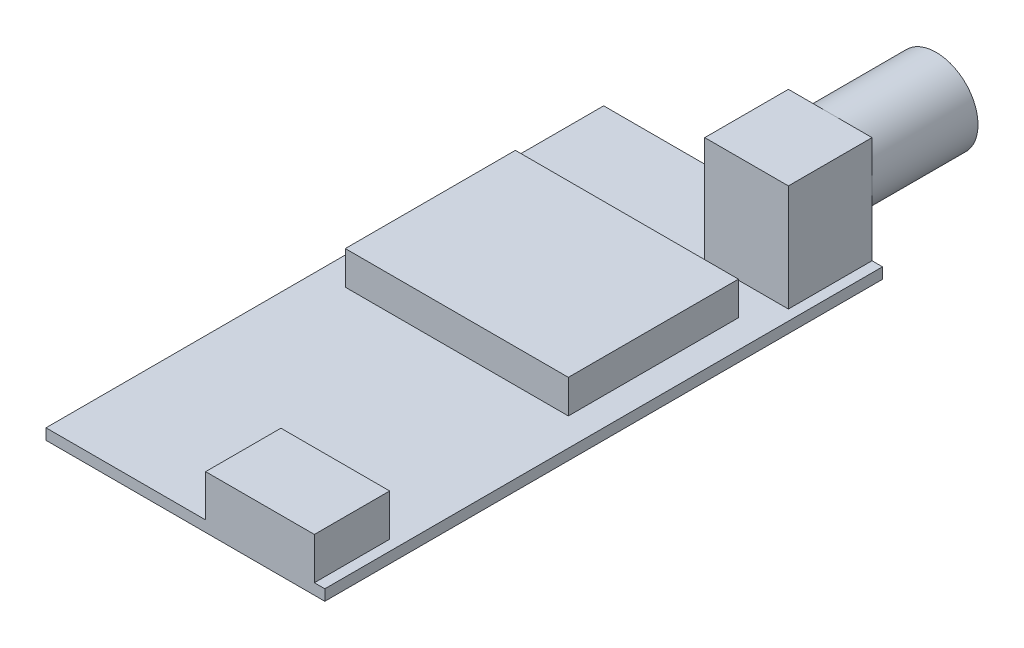
from build123d import *

# Parameters (mm, degrees)
SKETCH1_W           = 20
SKETCH1_H           = 40
BOSS_EXTRUDE1_DEPTH = 0.78
SKETCH4_W           = 6
SKETCH4_H           = 7.65
BOSS_EXTRUDE2_DEPTH = 6
SKETCH4_3_R         = 3
BOSS_EXTRUDE3_DEPTH = 7.6
SKETCH5_W           = 7.8
SKETCH5_H           = 5.4
BOSS_EXTRUDE4_DEPTH = 3
SKETCH6_W           = 16
SKETCH6_H           = 12.2
BOSS_EXTRUDE5_DEPTH = 2.4


with BuildPart() as part:
    # Sketch1 → Boss-Extrude1 (new body)
    with BuildSketch(Plane(origin=(0, 0, 0), x_dir=(1, 0, 0), z_dir=(0, 1, 0))):
        with Locations((0, -20)):
            Rectangle(SKETCH1_W, SKETCH1_H)
    extrude(amount=BOSS_EXTRUDE1_DEPTH)

    # Sketch4 → Boss-Extrude2 (add)
    with BuildSketch(Plane.XY):
        with Locations((6.25, 4.605)):
            Rectangle(SKETCH4_W, SKETCH4_H)
    extrude(amount=BOSS_EXTRUDE2_DEPTH)

    # Sketch4_3 → Boss-Extrude3 (add)
    with BuildSketch(Plane.XY):
        with Locations((6.25, 5.43)):
            Circle(SKETCH4_3_R)
    extrude(amount=-BOSS_EXTRUDE3_DEPTH)

    # Sketch5 → Boss-Extrude4 (add)
    with BuildSketch(Plane(origin=(0, 0.78, 0), x_dir=(1, 0, 0), z_dir=(0, 1, 0))):
        with Locations((5.35, -37.3)):
            Rectangle(SKETCH5_W, SKETCH5_H)
    extrude(amount=BOSS_EXTRUDE4_DEPTH)

    # Sketch6 → Boss-Extrude5 (add)
    with BuildSketch(Plane(origin=(0, 0.78, 0), x_dir=(1, 0, 0), z_dir=(0, 1, 0))):
        with Locations((0, -14.432954473)):
            Rectangle(SKETCH6_W, SKETCH6_H)
    extrude(amount=BOSS_EXTRUDE5_DEPTH)


solid = part.part
